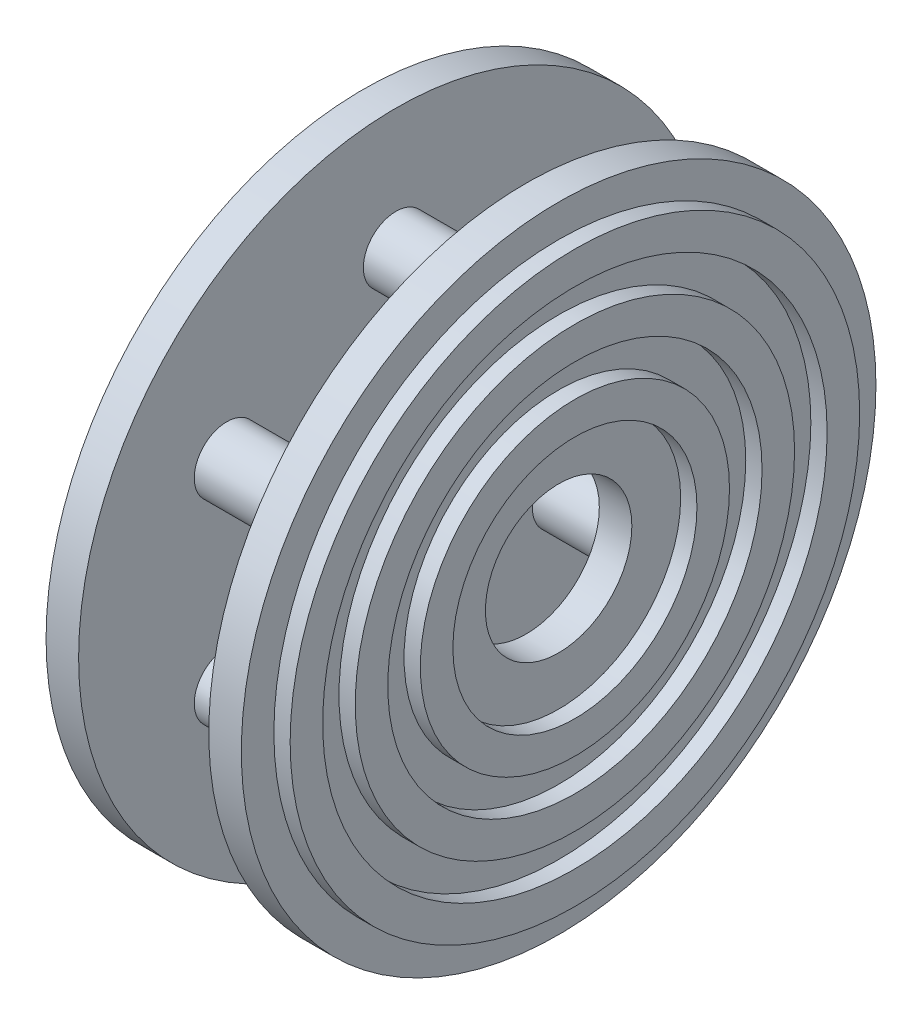
from build123d import *

# Parameters (mm, degrees)
SKETCH1_R           = 9.75
SKETCH1_R_2         = 2.25
BOSS_EXTRUDE1_DEPTH = 1
BOSS_EXTRUDE2_DEPTH = 0.5
SKETCH3_R           = 1
BOSS_EXTRUDE3_DEPTH = 4
SKETCH4_R           = 9.75
SKETCH4_R_2         = 2.25
BOSS_EXTRUDE4_DEPTH = 1


with BuildPart() as part:
    # Sketch1 → Boss-Extrude1 (new body)
    with BuildSketch(Plane(origin=(0, 0, 0), x_dir=(0, 0, -1), z_dir=(1, 0, 0))):
        Circle(SKETCH1_R)
        Circle(SKETCH1_R_2, mode=Mode.SUBTRACT)
    extrude(amount=BOSS_EXTRUDE1_DEPTH)

    # Sketch2 → Boss-Extrude2 (add)
    with BuildSketch(Plane(origin=(1, 0, 0), x_dir=(0, 0, -1), z_dir=(1, 0, 0))):
        with BuildLine():
            ThreePointArc((8.696853314, 0.96293428), (-0.96293428, 8.696853314), (-8.696853314, -0.96293428))
            ThreePointArc((-8.696853314, -0.96293428), (0.482199906, -8.736703226), (8.75, 0))
            ThreePointArc((8.75, 0), (8.736703226, 0.482199906), (8.696853314, 0.96293428))
        make_face()
        with BuildLine():
            ThreePointArc((7.75, 0), (0.427091345, -7.738222857), (-7.702927221, -0.852884648))
            ThreePointArc((-7.702927221, -0.852884648), (-0.852884648, 7.702927221), (7.702927221, 0.852884648))
            ThreePointArc((7.702927221, 0.852884648), (7.738222857, 0.427091345), (7.75, 0))
        make_face(mode=Mode.SUBTRACT)
        with BuildLine():
            ThreePointArc((6.709001128, 0.742835016), (-0.742835016, 6.709001128), (-6.709001128, -0.742835016))
            ThreePointArc((-6.709001128, -0.742835016), (0.371982785, -6.739742488), (6.75, 0))
            ThreePointArc((6.75, 0), (6.739742488, 0.371982785), (6.709001128, 0.742835016))
        make_face()
        with BuildLine():
            ThreePointArc((5.75, 0), (0.316874224, -5.74126212), (-5.715075035, -0.632785384))
            ThreePointArc((-5.715075035, -0.632785384), (-0.632785384, 5.715075035), (5.715075035, 0.632785384))
            ThreePointArc((5.715075035, 0.632785384), (5.74126212, 0.316874224), (5.75, 0))
        make_face(mode=Mode.SUBTRACT)
        with BuildLine():
            ThreePointArc((4.721148942, 0.522735752), (-0.522735752, 4.721148942), (-4.721148942, -0.522735752))
            ThreePointArc((-4.721148942, -0.522735752), (0.261765663, -4.742781751), (4.75, 0))
            ThreePointArc((4.75, 0), (4.742781751, 0.261765663), (4.721148942, 0.522735752))
        make_face()
        with BuildLine():
            ThreePointArc((3.75, 0), (0.206657103, -3.744301382), (-3.727222849, -0.41268612))
            ThreePointArc((-3.727222849, -0.41268612), (-0.41268612, 3.727222849), (3.727222849, 0.41268612))
            ThreePointArc((3.727222849, 0.41268612), (3.744301382, 0.206657103), (3.75, 0))
        make_face(mode=Mode.SUBTRACT)
    extrude(amount=BOSS_EXTRUDE2_DEPTH)

    # Sketch3 → Boss-Extrude3 (add)
    with BuildSketch(Plane.ZY):
        with Locations((0, 6)):
            Circle(SKETCH3_R)
        with Locations((5.196152423, 3)):
            Circle(SKETCH3_R)
        with Locations((5.196152423, -3)):
            Circle(SKETCH3_R)
        with Locations((0, -6)):
            Circle(SKETCH3_R)
        with Locations((-5.196152423, -3)):
            Circle(SKETCH3_R)
        with Locations((-5.196152423, 3)):
            Circle(SKETCH3_R)
    extrude(amount=BOSS_EXTRUDE3_DEPTH)

    # Sketch4 → Boss-Extrude4 (add)
    with BuildSketch(Plane.ZY.offset(4)):
        Circle(SKETCH4_R)
        Circle(SKETCH4_R_2, mode=Mode.SUBTRACT)
    extrude(amount=BOSS_EXTRUDE4_DEPTH)


solid = part.part
